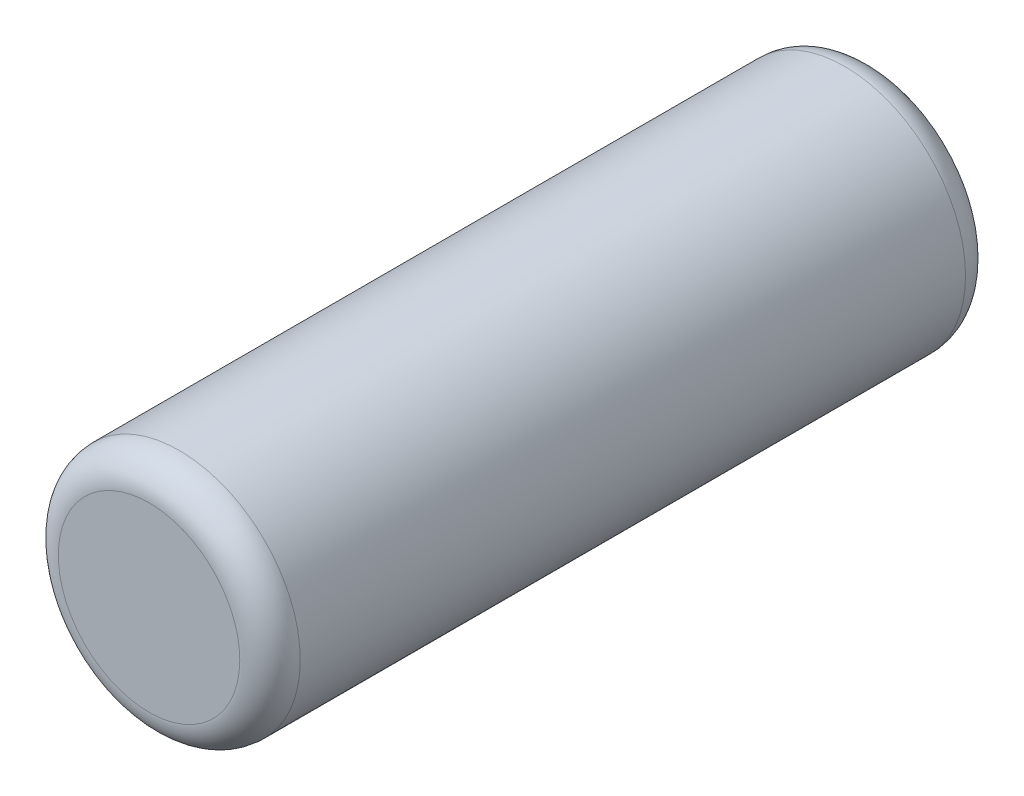
from build123d import *

# Parameters (mm, degrees)
BOSS_EXTRUDE1_DEPTH = 24
FILLET1_R           = 1


with BuildPart() as part:
    # Sketch1 → Boss-Extrude1 (new body)
    with BuildSketch(Plane.XY):
        with BuildLine():
            ThreePointArc((94, 0), (93.625231148, 1.690473047), (92.571150439, 3.064177772))
            ThreePointArc((92.571150439, 3.064177772), (86, 0), (92.571150439, -3.064177772))
            ThreePointArc((92.571150439, -3.064177772), (93.625231148, -1.690473047), (94, 0))
        make_face()
    extrude(amount=BOSS_EXTRUDE1_DEPTH)

    # Fillet1
    fillet1_edges = [part.edges().sort_by_distance(p)[0] for p in [
        (87.428849561, 3.064177772, 0),
        (87.428849561, 3.064177772, 24),
    ]]
    fillet(fillet1_edges, radius=FILLET1_R)


solid = part.part
